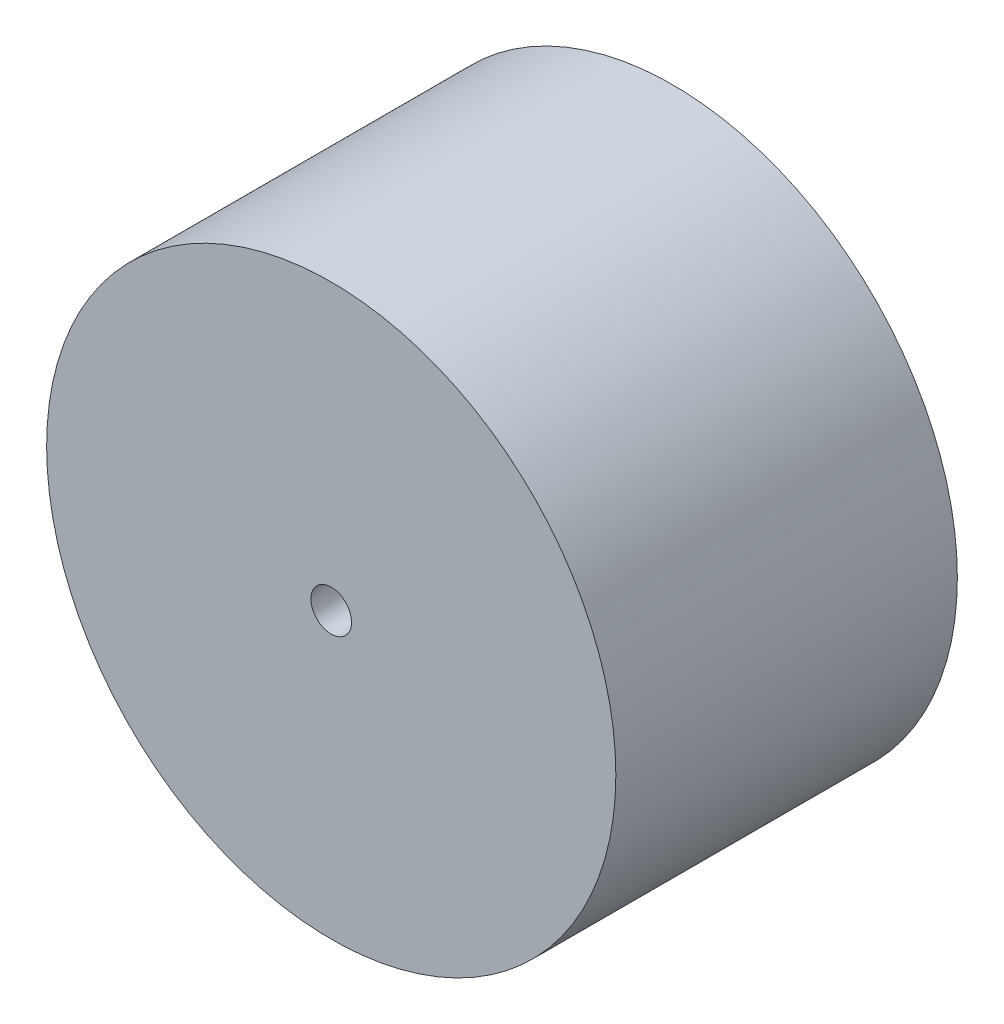
from build123d import *

# Parameters (mm, degrees)
SKETCH1_R           = 35
SKETCH1_R_2         = 2.5
BOSS_EXTRUDE1_DEPTH = 42


with BuildPart() as part:
    # Sketch1 → Boss-Extrude1 (new body)
    with BuildSketch(Plane.XY):
        Circle(SKETCH1_R)
        Circle(SKETCH1_R_2, mode=Mode.SUBTRACT)
    extrude(amount=BOSS_EXTRUDE1_DEPTH)


solid = part.part
